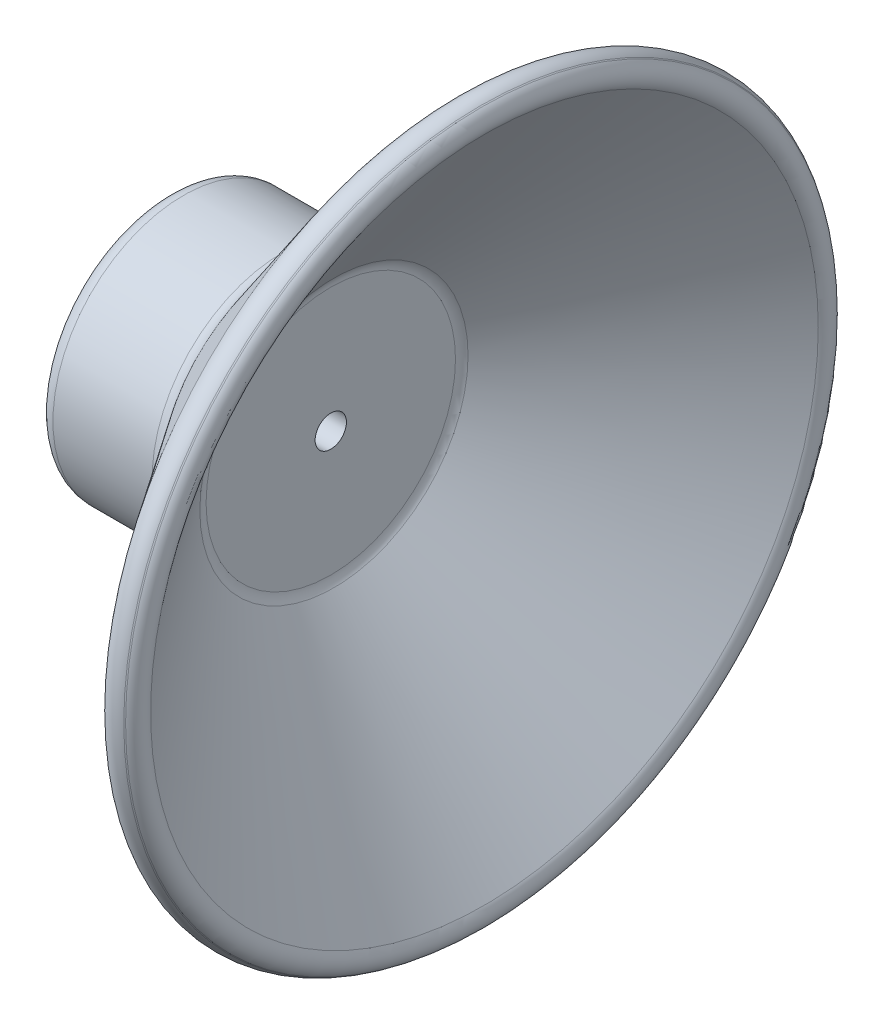
from build123d import *

# Parameters (mm, degrees)
SKETCH3_R          = 1.524
CUT_EXTRUDE1_DEPTH = 19.439713487


with BuildPart() as part:
    # Sketch2 → Revolve1 (revolve)
    with BuildSketch(Plane(origin=(0, 0, 0), x_dir=(1, 0, 0), z_dir=(0, 1, 0))):
        with BuildLine():
            Line((-17.336950759, 11.049), (-17.336950759, 11.176))
            ThreePointArc((-17.336950759, 11.176), (-16.890581493, 12.253630735), (-15.812950759, 12.7))
            Line((-15.812950759, 12.7), (-6.160950759, 12.7))
            ThreePointArc((-6.160950759, 12.7), (-5.480945291, 12.860120033), (-4.943830241, 13.306833905))
            Line((-4.943830241, 13.306833905), (10.960215402, 34.412215318))
            ThreePointArc((10.960215402, 34.412215318), (11.965236113, 35.00421776), (13.094502014, 34.71216974))
            Line((13.094502014, 34.71216974), (13.195928724, 34.635739232))
            ThreePointArc((13.195928724, 34.635739232), (13.787931166, 33.630718521), (13.495883146, 32.50145262))
            Line((13.495883146, 32.50145262), (-1.155071276, 13.058979422))
            ThreePointArc((-1.155071276, 13.058979422), (-1.383196009, 12.625385623), (-1.461950759, 12.141813327))
            Line((-1.461950759, 12.141813327), (-1.461950759, 0))
            Line((-1.461950759, 0), (-4.636950759, 0))
            Line((-4.636950759, 0), (-4.636950759, 8.001))
            ThreePointArc((-4.636950759, 8.001), (-5.083320024, 9.078630735), (-6.160950759, 9.525))
            Line((-6.160950759, 9.525), (-15.812950759, 9.525))
            ThreePointArc((-15.812950759, 9.525), (-16.890581493, 9.971369265), (-17.336950759, 11.049))
        make_face()
    revolve(axis=Axis((-1.461950759, 0, 0), (-1, 0, 0)))

    # Sketch3 → Cut-Extrude1 (cut, through all)
    with BuildSketch(Plane.ZY.offset(4.636950759)):
        Circle(SKETCH3_R)
    extrude(amount=-CUT_EXTRUDE1_DEPTH, mode=Mode.SUBTRACT)


solid = part.part
